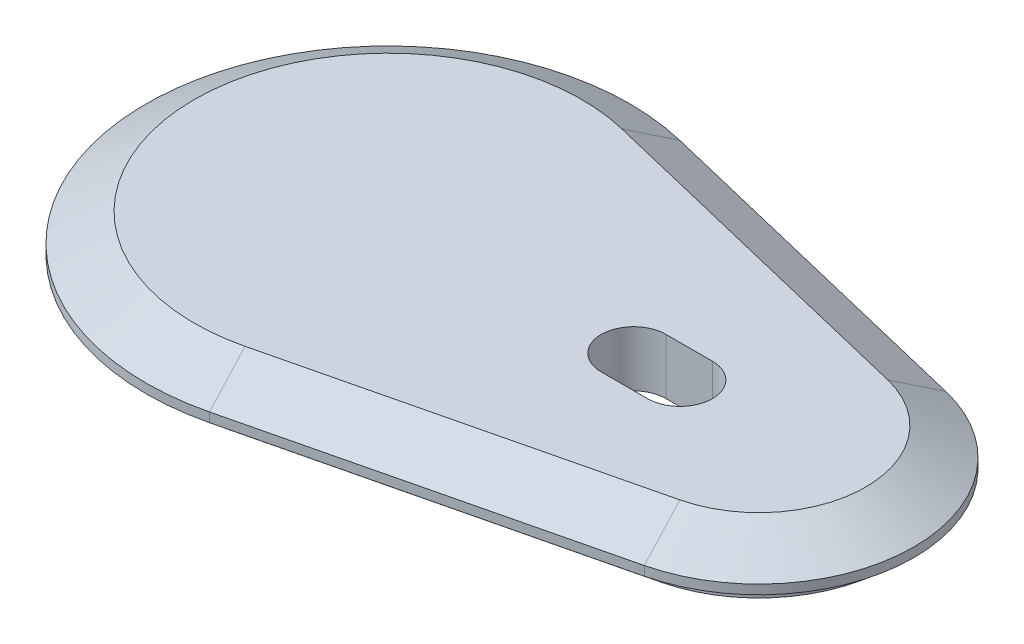
from build123d import *

# Parameters (mm, degrees)
BOSS_EXTRUDE1_DEPTH           = 3
BOSS_EXTRUDE1_TAPER           = 60
BOSS_EXTRUDE1_OTHER_WAY_DEPTH = 1
BOSS_EXTRUDE2_DEPTH           = 3
CUT_EXTRUDE1_DEPTH            = 7


with BuildPart() as part:
    # Sketch2 → Boss-Extrude1 (new body)
    with BuildSketch(Plane(origin=(0, 0, 0), x_dir=(1, 0, 0), z_dir=(0, 1, 0))):
        with BuildLine():
            Line((6.113925, -25.373803836), (43.9190025, -16.264511041))
            ThreePointArc((43.9190025, -16.264511041), (56.73, 0), (43.9190025, 16.264511041))
            Line((43.9190025, 16.264511041), (6.113925, 25.373803836))
            ThreePointArc((6.113925, 25.373803836), (-26.1, 0), (6.113925, -25.373803836))
        make_face()
    extrude(amount=BOSS_EXTRUDE1_DEPTH, taper=BOSS_EXTRUDE1_TAPER)

    # Sketch2 → Boss-Extrude1 other way (add)
    with BuildSketch(Plane(origin=(0, 0, 0), x_dir=(1, 0, 0), z_dir=(0, 1, 0))):
        with BuildLine():
            Line((6.113925, -25.373803836), (43.9190025, -16.264511041))
            ThreePointArc((43.9190025, -16.264511041), (56.73, 0), (43.9190025, 16.264511041))
            Line((43.9190025, 16.264511041), (6.113925, 25.373803836))
            ThreePointArc((6.113925, 25.373803836), (-26.1, 0), (6.113925, -25.373803836))
        make_face()
    extrude(amount=-BOSS_EXTRUDE1_OTHER_WAY_DEPTH)

    # Sketch1 → Boss-Extrude2 (add)
    with BuildSketch(Plane(origin=(0, 0, 0), x_dir=(1, 0, 0), z_dir=(0, 1, 0))):
        with BuildLine():
            Line((5.551725, 23.040580495), (43.3568025, 13.9312877))
            ThreePointArc((43.3568025, 13.9312877), (54.33, 0), (43.3568025, -13.9312877))
            Line((43.3568025, -13.9312877), (5.551725, -23.040580495))
            ThreePointArc((5.551725, -23.040580495), (-23.7, 0), (5.551725, 23.040580495))
        make_face()
    extrude(amount=-BOSS_EXTRUDE2_DEPTH)

    # Sketch3 → Cut-Extrude1 (cut, through all)
    with BuildSketch(Plane(origin=(0, 3, 0), x_dir=(1, 0, 0), z_dir=(0, 1, 0))):
        with BuildLine():
            Line((31.5, -3.5), (26.5, -3.5))
            ThreePointArc((26.5, -3.5), (23, 0), (26.5, 3.5))
            Line((26.5, 3.5), (31.5, 3.5))
            ThreePointArc((31.5, 3.5), (35, 0), (31.5, -3.5))
        make_face()
    extrude(amount=-CUT_EXTRUDE1_DEPTH, mode=Mode.SUBTRACT)


solid = part.part
